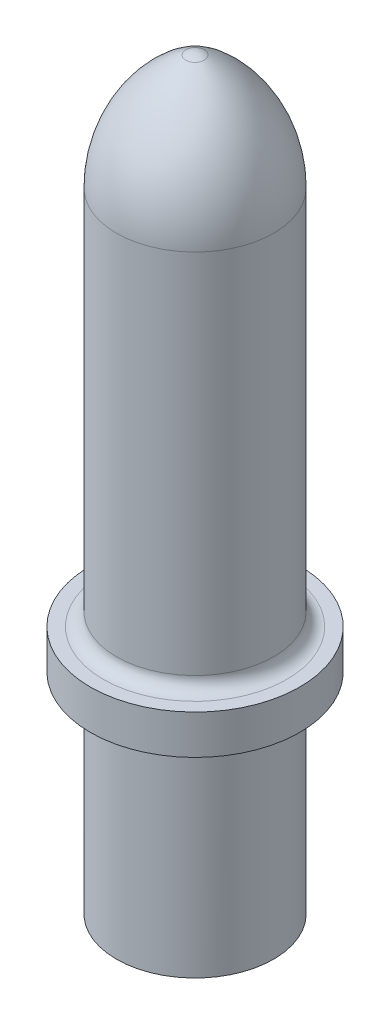
from build123d import *

# Parameters (mm, degrees)
FILLET1_R = 3.175


with BuildPart() as part:
    # Sketch1 → Revolve2 (revolve)
    with BuildSketch(Plane.XY):
        with BuildLine():
            Line((-25.4, -6.141632853), (-25.4, 3.383367147))
            Line((-25.4, 3.383367147), (-19.05, 3.383367147))
            Line((-19.05, 3.383367147), (-19.05, 95.458367147))
            ThreePointArc((-19.05, 95.458367147), (-14.517976471, 111.753635849), (-2.223442899, 123.369119633))
            ThreePointArc((-2.223442899, 123.369119633), (-1.145335288, 123.78023171), (0, 123.9200038))
            Line((0, 123.9200038), (0, 95.458367147))
            Line((0, 95.458367147), (0, 0))
            Line((0, 0), (0, -56.941632853))
            Line((0, -56.941632853), (-19.05, -56.941632853))
            Line((-19.05, -56.941632853), (-19.05, -6.141632853))
            Line((-19.05, -6.141632853), (-25.4, -6.141632853))
        make_face()
    revolve(axis=Axis((0, 95.458367147, 0), (0, -1, 0)))

    # Fillet1
    fillet1_edges = [part.edges().sort_by_distance(p)[0] for p in [
        (19.05, 3.383367147, 0),
        (19.05, -6.141632853, 0),
    ]]
    fillet(fillet1_edges, radius=FILLET1_R)


solid = part.part
